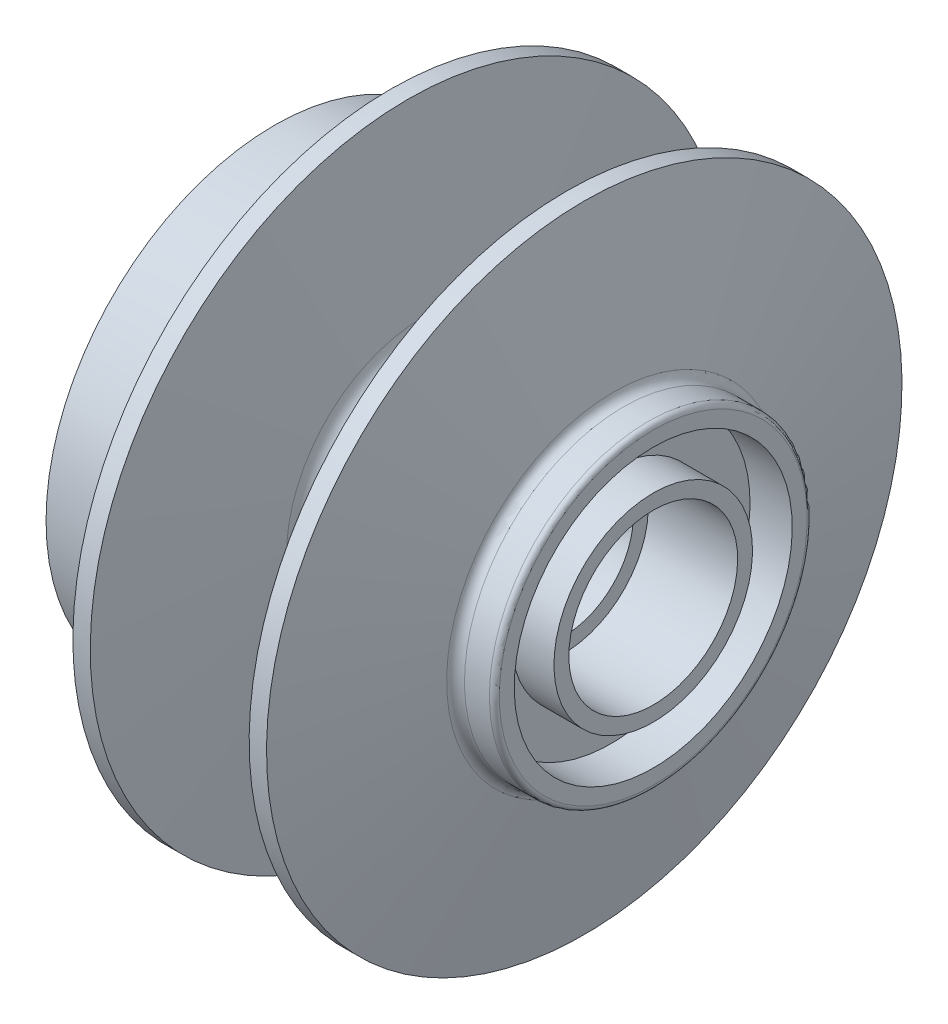
from build123d import *

# Parameters (mm, degrees)
CUT_EXTRUDE1_DEPTH = 20


with BuildPart() as part:
    # Sketch1 → Revolve3 (revolve)
    with BuildSketch(Plane.XY):
        with BuildLine():
            Line((-48.189932556, 17), (-25.189932556, 17))
            Line((-25.189932556, 17), (-25.189932556, 14))
            Line((-25.189932556, 14), (-4.689932556, 14))
            ThreePointArc((-4.689932556, 14), (-4.336379165, 13.853553391), (-4.189932556, 13.5))
            Line((-4.189932556, 13.5), (-4.189932556, 10))
            Line((-4.189932556, 10), (-3.189932556, 10))
            Line((-3.189932556, 10), (-3.189932556, 13.5))
            ThreePointArc((-3.189932556, 13.5), (-3.043485946, 13.853553391), (-2.689932556, 14))
            Line((-2.689932556, 14), (17.810067444, 14))
            Line((17.810067444, 14), (17.810067444, 17))
            Line((17.810067444, 17), (35.810067444, 17))
            Line((35.810067444, 17), (35.810067444, 20))
            Line((35.810067444, 20), (27.310067444, 20))
            Line((27.310067444, 20), (27.310067444, 28))
            Line((27.310067444, 28), (35.810067444, 28))
            Line((35.810067444, 28), (35.810067444, 31))
            ThreePointArc((35.810067444, 31), (35.517174226, 31.707106781), (34.810067444, 32))
            Line((34.810067444, 32), (29.785312195, 32))
            ThreePointArc((29.785312195, 32), (28.513155754, 32.456750833), (27.822057828, 33.618382009))
            Line((27.822057828, 33.618382009), (21.91646953, 64))
            Line((21.91646953, 64), (18.41646953, 64))
            Line((18.41646953, 64), (15.236377086, 27.651377029))
            ThreePointArc((15.236377086, 27.651377029), (13.953959124, 25.050890653), (11.251598293, 24))
            Line((11.251598293, 24), (-6.418659232, 24))
            ThreePointArc((-6.418659232, 24), (-9.121020063, 25.050890653), (-10.403438025, 27.651377029))
            Line((-10.403438025, 27.651377029), (-13.58353047, 64))
            Line((-13.58353047, 64), (-17.08353047, 64))
            Line((-17.08353047, 64), (-18.416800204, 48.760657201))
            ThreePointArc((-18.416800204, 48.760657201), (-18.705888121, 48.140706163), (-19.325839159, 47.851618246))
            Line((-19.325839159, 47.851618246), (-40.489932556, 46))
            Line((-40.489932556, 46), (-40.489932556, 28))
            Line((-40.489932556, 28), (-44.489932556, 28))
            Line((-44.489932556, 28), (-44.489932556, 23))
            ThreePointArc((-44.489932556, 23), (-44.782825774, 22.292893219), (-45.489932556, 22))
            Line((-45.489932556, 22), (-46.189932556, 22))
            ThreePointArc((-46.189932556, 22), (-47.604146118, 21.414213562), (-48.189932556, 20))
            Line((-48.189932556, 20), (-48.189932556, 17))
        make_face()
    revolve(axis=Axis((62.091155106, 0, 0), (-1, 0, 0)))

    # Sketch2 → Cut-Extrude1 (cut)
    with BuildSketch(Plane.ZY.offset(40.489932556)):
        with BuildLine():
            Line((-38.557564416, 6.798738917), (-36.600549398, 6.453664368))
            ThreePointArc((-36.600549398, 6.453664368), (-33.14449737, 7.099475286), (-30.968000708, 9.860676048))
            ThreePointArc((-30.968000708, 9.860676048), (-22.980970389, 22.980970389), (-9.860676048, 30.968000708))
            ThreePointArc((-9.860676048, 30.968000708), (-7.099475286, 33.14449737), (-6.453664368, 36.600549398))
            Line((-6.453664368, 36.600549398), (-6.798738917, 38.557564416))
            ThreePointArc((-6.798738917, 38.557564416), (-12.059367939, 38.046386934), (-15.036732198, 42.413402184))
            ThreePointArc((-15.036732198, 42.413402184), (-31.819805153, 31.819805153), (-42.413402184, 15.036732198))
            ThreePointArc((-42.413402184, 15.036732198), (-38.046386934, 12.059367939), (-38.557564416, 6.798738917))
        make_face()
    extrude(amount=-CUT_EXTRUDE1_DEPTH, mode=Mode.SUBTRACT)


solid = part.part
